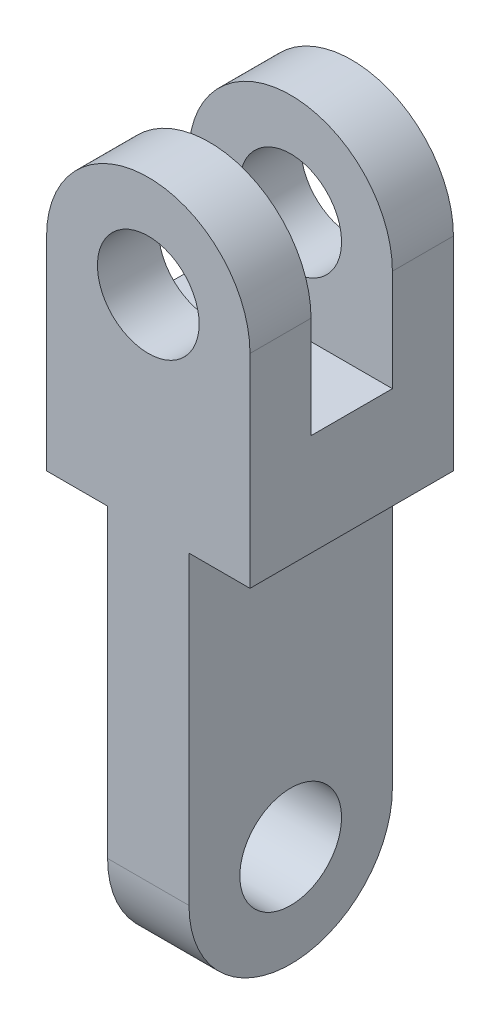
from build123d import *

# Parameters (mm, degrees)
CROQUIS1_R              = 25
SALIENTE_EXTRUIR1_DEPTH = 50
CORTAR_EXTRUIR1_REACH   = 102
CROQUIS2_W              = 40
CROQUIS2_H              = 100
CROQUIS3_R              = 25
SALIENTE_EXTRUIR2_DEPTH = 20


with BuildPart() as part:
    # Croquis1 → Saliente-Extruir1 (new body, symmetric)
    with BuildSketch(Plane.XY):
        with BuildLine():
            Line((-50, 0), (50, 0))
            Line((50, 0), (50, 100))
            ThreePointArc((50, 100), (0, 150), (-50, 100))
            Line((-50, 100), (-50, 0))
        make_face()
        with Locations((0, 100)):
            Circle(CROQUIS1_R, mode=Mode.SUBTRACT)
    extrude(amount=SALIENTE_EXTRUIR1_DEPTH, both=True)

    # Croquis2 → Cortar-Extruir1 (cut, up to next)
    with BuildSketch(Plane(origin=(50, 0, 0), x_dir=(0, 0, -1), z_dir=(1, 0, 0)), mode=Mode.PRIVATE) as cortar_extruir1_sk1:
        with Locations((0, 100)):
            Rectangle(CROQUIS2_W, CROQUIS2_H)
    cortar_extruir1_tool1 = extrude(cortar_extruir1_sk1.sketch, amount=-CORTAR_EXTRUIR1_REACH, mode=Mode.PRIVATE) & part.part
    add(cortar_extruir1_tool1.solids().sort_by_distance((50, 100, 0))[0], mode=Mode.SUBTRACT)

    # Croquis3 → Saliente-Extruir2 (add, symmetric)
    with BuildSketch(Plane(origin=(0, 0, 0), x_dir=(0, 0, -1), z_dir=(1, 0, 0))):
        with BuildLine():
            Line((-50, 0), (-50, -150))
            ThreePointArc((-50, -150), (0, -200), (50, -150))
            Line((50, -150), (50, 0))
            Line((50, 0), (-50, 0))
        make_face()
        with Locations((0, -150)):
            Circle(CROQUIS3_R, mode=Mode.SUBTRACT)
    extrude(amount=SALIENTE_EXTRUIR2_DEPTH, both=True)


solid = part.part
